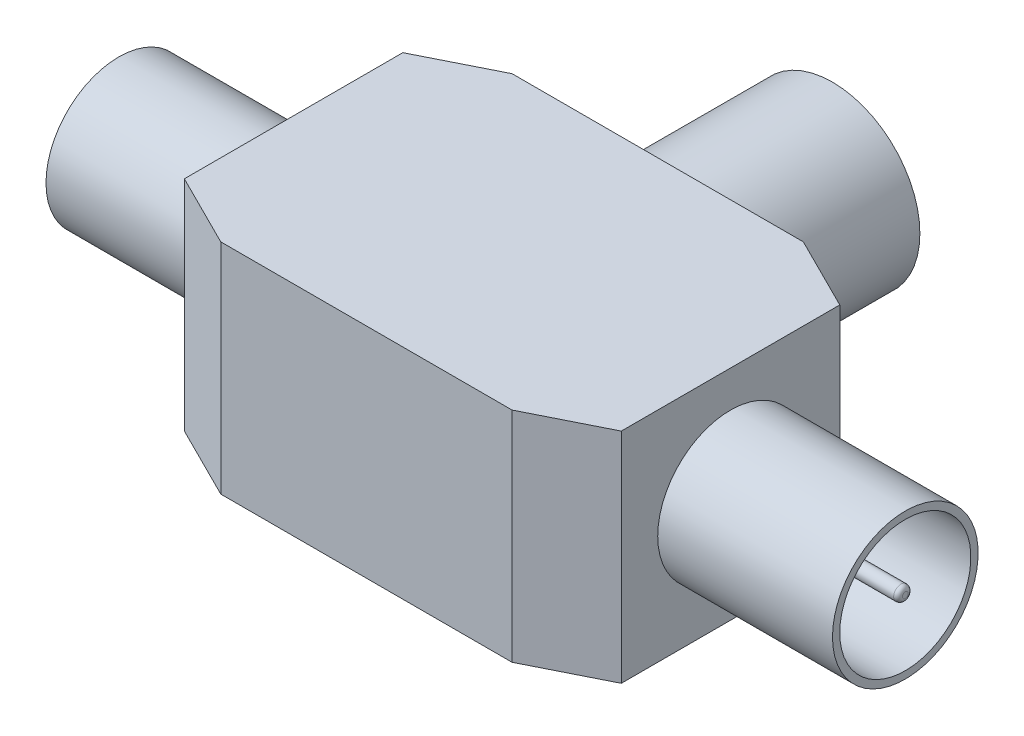
from build123d import *

# Parameters (mm, degrees)
BOSS_EXTRUDE1_DEPTH  = 15
SKETCH2_R            = 6
SKETCH2_R_2          = 5.5
BOSS_EXTRUDE2_DEPTH  = 12
SKETCH3_R            = 1
SKETCH3_R_2          = 0.8
BOSS_EXTRUDE3_DEPTH  = 12
SKETCH4_R            = 5
SKETCH4_R_2          = 4.5
SKETCH4_R_3          = 0.5
BOSS_EXTRUDE4_DEPTH  = 12
FILLET2_R            = 0.3
FILLET2_OF_MIRROR1_R = 0.3


with BuildPart() as part:
    # Sketch1 → Boss-Extrude1 (new body)
    with BuildSketch(Plane(origin=(0, 0, 0), x_dir=(1, 0, 0), z_dir=(0, 1, 0))):
        Polygon((10, 20), (15, 17.5), (15, 2.5), (10, 0), (-10, 0), (-15, 2.5), (-15, 17.5), (-10, 20), align=None)
    extrude(amount=BOSS_EXTRUDE1_DEPTH)

    # Sketch2 → Boss-Extrude2 (add)
    with BuildSketch(Plane(origin=(0, 0, -20), x_dir=(-1, 0, 0), z_dir=(0, 0, -1))):
        with Locations((0, 7.5)):
            Circle(SKETCH2_R)
        with Locations((0, 7.5)):
            Circle(SKETCH2_R_2, mode=Mode.SUBTRACT)
    extrude(amount=BOSS_EXTRUDE2_DEPTH)

    # Sketch3 → Boss-Extrude3 (add)
    with BuildSketch(Plane(origin=(0, 0, -20), x_dir=(-1, 0, 0), z_dir=(0, 0, -1))):
        with Locations((0, 7.5)):
            Circle(SKETCH3_R)
        with Locations((0, 7.5)):
            Circle(SKETCH3_R_2, mode=Mode.SUBTRACT)
    extrude(amount=BOSS_EXTRUDE3_DEPTH)

    # Sketch4 → Boss-Extrude4 (add)
    with BuildSketch(Plane.ZY.offset(15)):
        with Locations((-10, 7.5)):
            Circle(SKETCH4_R)
        with Locations((-10, 7.5)):
            Circle(SKETCH4_R_2, mode=Mode.SUBTRACT)
        with Locations((-10, 7.5)):
            Circle(SKETCH4_R_3)
    boss_extrude4 = extrude(amount=BOSS_EXTRUDE4_DEPTH)

    # Fillet2
    fillet2_edges = [part.edges().sort_by_distance(p)[0] for p in [
        (-27, 7.5, -10.5),
    ]]
    fillet(fillet2_edges, radius=FILLET2_R)

    # Mirror1: Boss-Extrude4 across plane
    add(boss_extrude4.mirror(Plane(origin=(0, 0, 0), x_dir=(0, 0, 1), z_dir=(1, 0, 0))))

    # Fillet2 of Mirror1
    fillet2_of_mirror1_edges = [part.edges().sort_by_distance(p)[0] for p in [
        (27, 7.5, -10.5),
    ]]
    fillet(fillet2_of_mirror1_edges, radius=FILLET2_OF_MIRROR1_R)


solid = part.part
